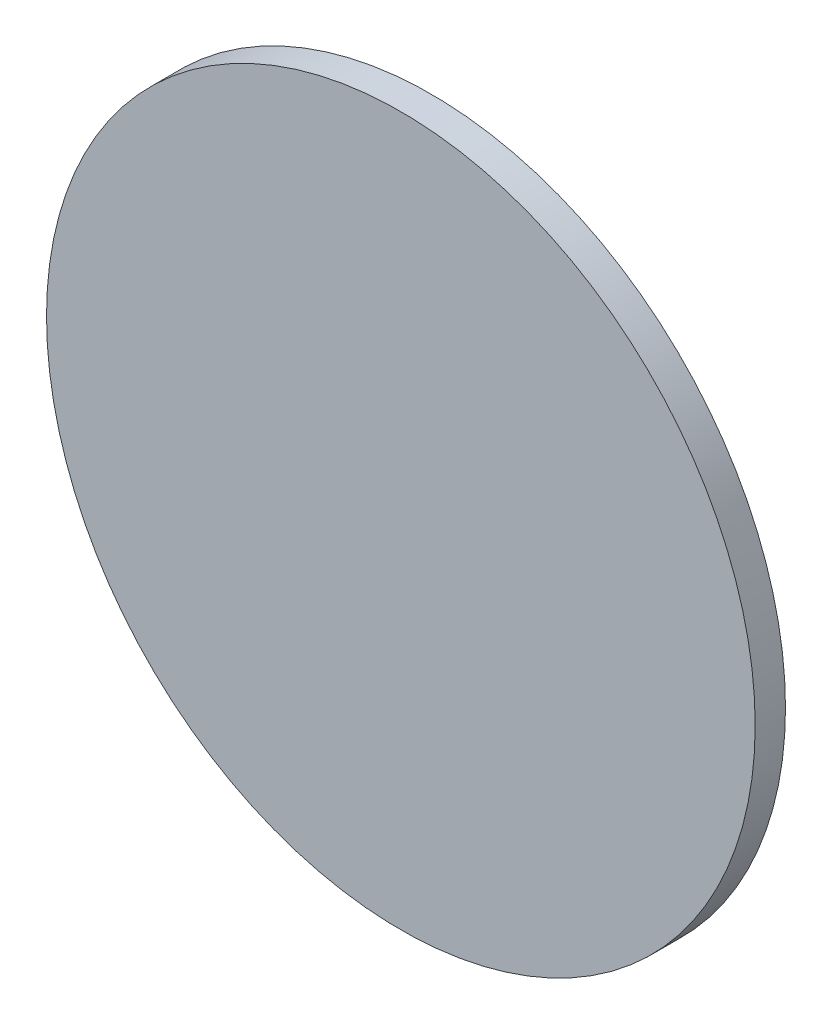
from build123d import *

# Parameters (mm, degrees)
SKETCH1_R           = 74.295
BOSS_EXTRUDE1_DEPTH = 6.35


with BuildPart() as part:
    # Sketch1 → Boss-Extrude1 (new body)
    with BuildSketch(Plane.XY):
        Circle(SKETCH1_R)
    extrude(amount=BOSS_EXTRUDE1_DEPTH)


solid = part.part
